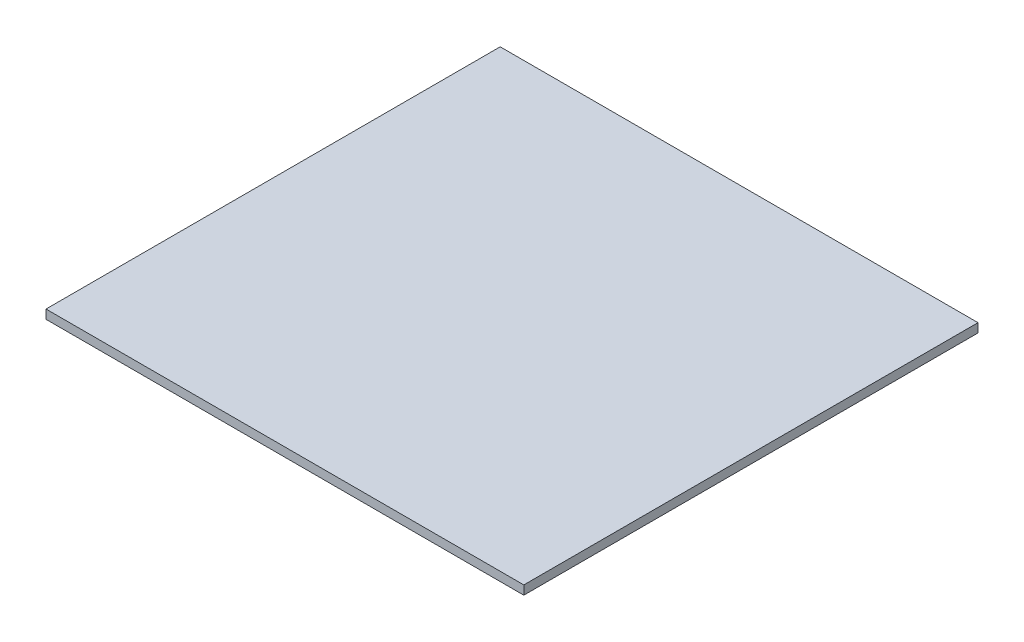
from build123d import *

# Parameters (mm, degrees)
SKETCH2_W = 91
SKETCH2_H = 86.5
PCB_DEPTH = 1.7


with BuildPart() as part:
    # Sketch2 → PCB (new body)
    with BuildSketch(Plane(origin=(0, 0, 0), x_dir=(1, 0, 0), z_dir=(0, 1, 0))):
        with Locations((45.5, 43.25)):
            Rectangle(SKETCH2_W, SKETCH2_H)
    extrude(amount=PCB_DEPTH)


solid = part.part
